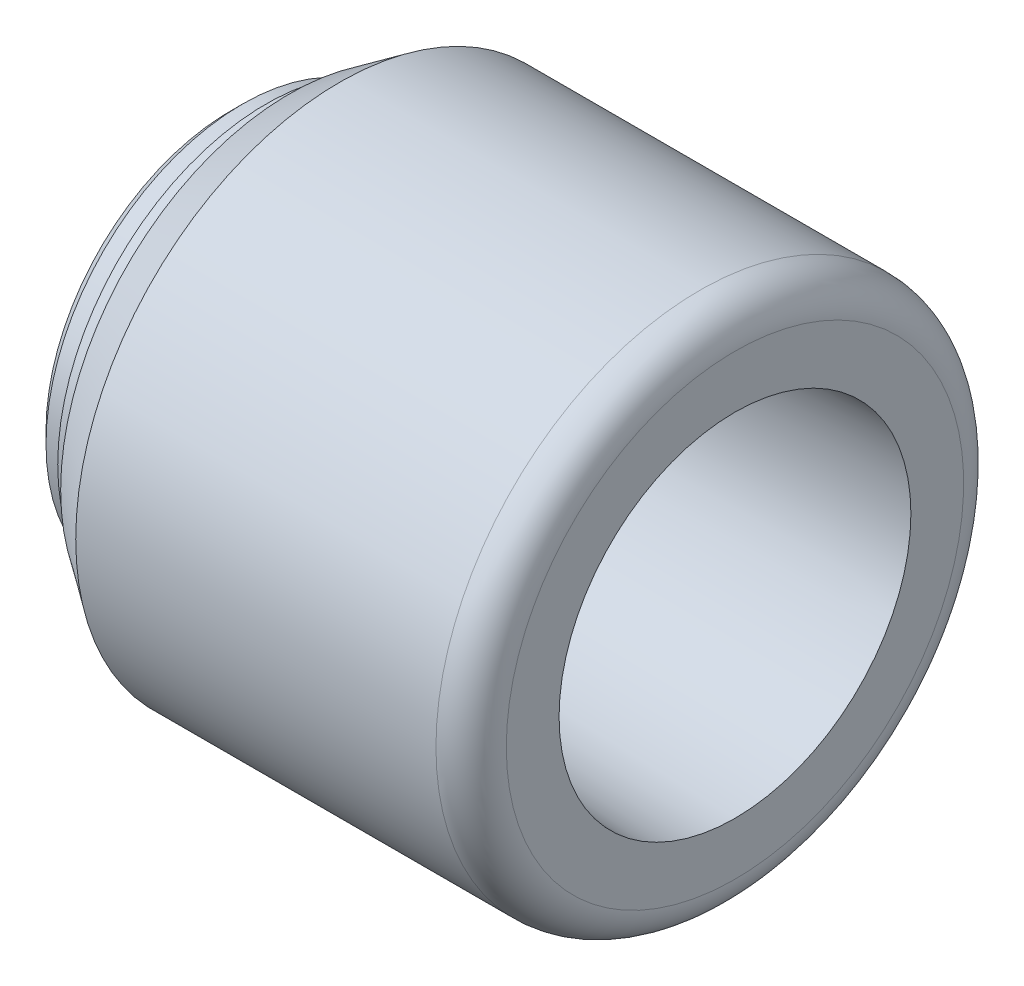
from build123d import *


with BuildPart() as part:
    # Sketch1 → Revolve1 (revolve)
    with BuildSketch(Plane.XY):
        with BuildLine():
            Line((1, 16.75), (0, 15.75))
            Line((0, 15.75), (0, 5.1))
            Line((0, 5.1), (15, 5.1))
            Line((15, 5.1), (15, 13.249667434))
            ThreePointArc((15, 13.249667434), (15.22452816, 13.805394131), (15.772080403, 14.049180096))
            Line((15.772080403, 14.049180096), (43, 15))
            Line((43, 15), (43, 19.5))
            ThreePointArc((43, 19.5), (42.121320344, 21.621320344), (40, 22.5))
            Line((40, 22.5), (9.28444402, 22.5))
            Line((9.28444402, 22.5), (5, 19.5))
            Line((5, 19.5), (5, 17.75))
            Line((5, 17.75), (3, 17.75))
            Line((3, 17.75), (3, 16.75))
            Line((3, 16.75), (1, 16.75))
        make_face()
    revolve(axis=Axis((0, 0, 0), (1, 0, 0)))


solid = part.part
